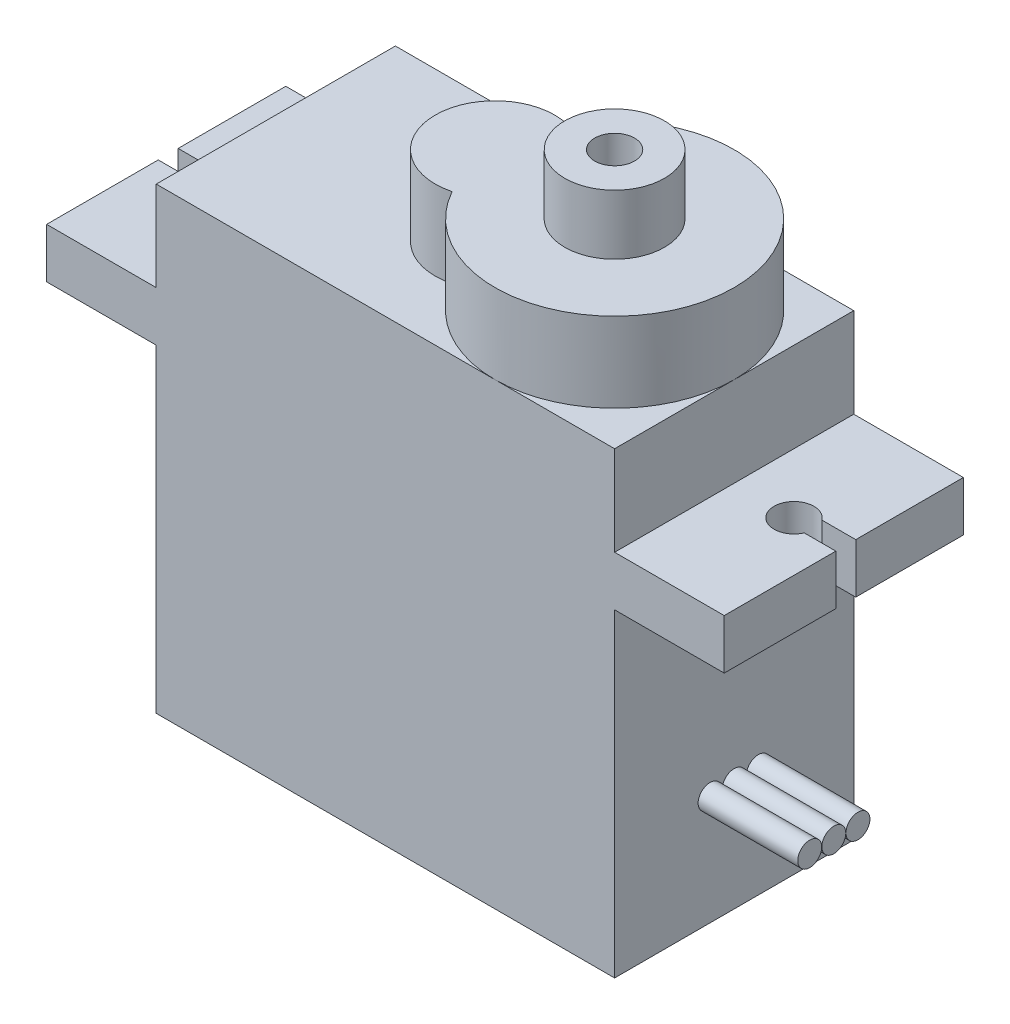
from build123d import *

# Parameters (mm, degrees)
SKETCH1_W           = 23
SKETCH1_H           = 12
BOSS_EXTRUDE1_DEPTH = 23
SKETCH2_W           = 12
SKETCH2_H           = 2.5
BOSS_EXTRUDE2_DEPTH = 5.5
CUT_EXTRUDE1_DEPTH  = 5
BOSS_EXTRUDE3_DEPTH = 4
SKETCH5_R           = 2.5
SKETCH5_R_2         = 1
BOSS_EXTRUDE4_DEPTH = 3
SKETCH7_R           = 0.6
BOSS_EXTRUDE8_DEPTH = 5


with BuildPart() as part:
    # Sketch1 → Boss-Extrude1 (new body)
    with BuildSketch(Plane(origin=(0, 0, 0), x_dir=(1, 0, 0), z_dir=(0, 1, 0))):
        Rectangle(SKETCH1_W, SKETCH1_H)
    extrude(amount=BOSS_EXTRUDE1_DEPTH)

    # Sketch2 → Boss-Extrude2 (add)
    with BuildSketch(Plane.ZY.offset(11.5)):
        with Locations((0, 17.25)):
            Rectangle(SKETCH2_W, SKETCH2_H)
    boss_extrude2 = extrude(amount=BOSS_EXTRUDE2_DEPTH)

    # Sketch3 → Cut-Extrude1 (cut)
    with BuildSketch(Plane(origin=(0, 18.5, 0), x_dir=(1, 0, 0), z_dir=(0, 1, 0))):
        with BuildLine():
            Line((-17, 0.6), (-15.3, 0.6))
            ThreePointArc((-15.3, 0.6), (-13.506719548, -0.11573221), (-15.416515139, -0.4))
            Line((-15.416515139, -0.4), (-17, -0.4))
            Line((-17, -0.4), (-17, 0.6))
        make_face()
    cut_extrude1 = extrude(amount=-CUT_EXTRUDE1_DEPTH, mode=Mode.SUBTRACT)

    # Mirror1: Boss-Extrude2, Cut-Extrude1 across plane
    add(boss_extrude2.mirror(Plane(origin=(0, 0, 0), x_dir=(0, 0, 1), z_dir=(1, 0, 0))))
    add(cut_extrude1.mirror(Plane(origin=(0, 0, 0), x_dir=(0, 0, 1), z_dir=(1, 0, 0))), mode=Mode.SUBTRACT)

    # Sketch4 → Boss-Extrude3 (add)
    with BuildSketch(Plane(origin=(0, 23, 0), x_dir=(1, 0, 0), z_dir=(0, 1, 0))):
        with BuildLine():
            ThreePointArc((0.25, -2.90473751), (11.5, 0), (0.25, 2.90473751))
            ThreePointArc((0.25, 2.90473751), (-3.5, 0), (0.25, -2.90473751))
        make_face()
    extrude(amount=BOSS_EXTRUDE3_DEPTH)

    # Sketch5 → Boss-Extrude4 (add)
    with BuildSketch(Plane(origin=(0, 27, 0), x_dir=(1, 0, 0), z_dir=(0, 1, 0))):
        with Locations((5.5, 0)):
            Circle(SKETCH5_R)
        with Locations((5.5, 0)):
            Circle(SKETCH5_R_2, mode=Mode.SUBTRACT)
    extrude(amount=BOSS_EXTRUDE4_DEPTH)

    # Sketch7 → Boss-Extrude8 (add)
    with BuildSketch(Plane(origin=(11.5, 0, 0), x_dir=(0, 0, -1), z_dir=(1, 0, 0))):
        with Locations((0, 5.5)):
            Circle(SKETCH7_R)
        with Locations((1.21, 5.5)):
            Circle(SKETCH7_R)
        with Locations((-1.21, 5.5)):
            Circle(SKETCH7_R)
    extrude(amount=BOSS_EXTRUDE8_DEPTH)


solid = part.part
